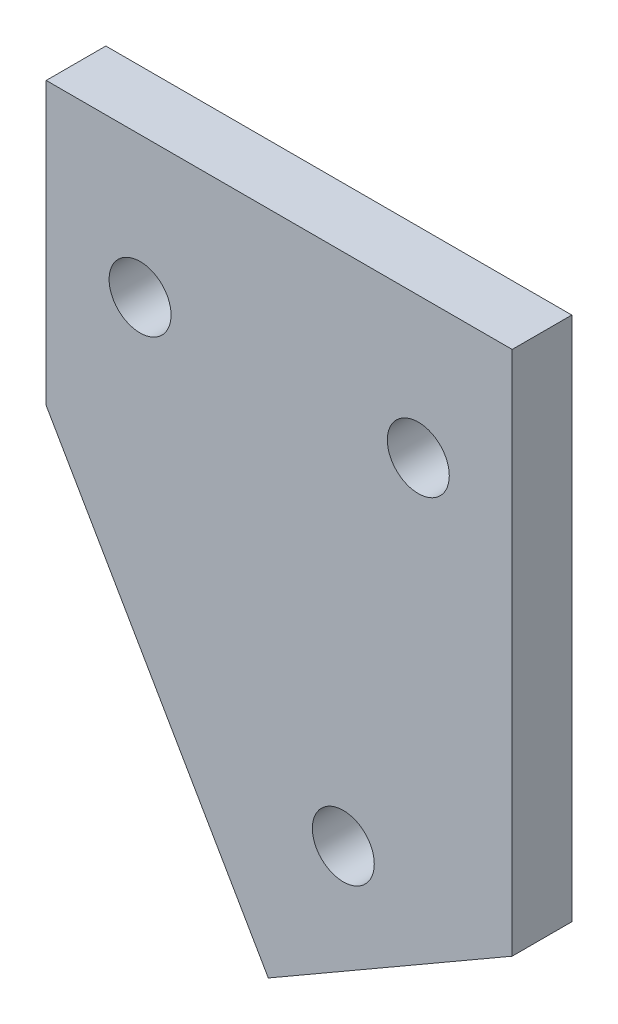
from build123d import *

# Parameters (mm, degrees)
SKETCH1_R           = 1.65
BOSS_EXTRUDE1_DEPTH = 3.175


with BuildPart() as part:
    # Sketch1 → Boss-Extrude1 (new body)
    with BuildSketch(Plane.XY):
        Polygon((0, 0), (11.830127019, -20.490381057), (24.820508076, -12.990381057), (24.820508076, 15), (0, 15), align=None)
        with Locations((15.825317547, -12.410254038)):
            Circle(SKETCH1_R, mode=Mode.SUBTRACT)
        with Locations((5, 7.5)):
            Circle(SKETCH1_R, mode=Mode.SUBTRACT)
        with Locations((19.820508076, 7.5)):
            Circle(SKETCH1_R, mode=Mode.SUBTRACT)
    extrude(amount=BOSS_EXTRUDE1_DEPTH)


solid = part.part
